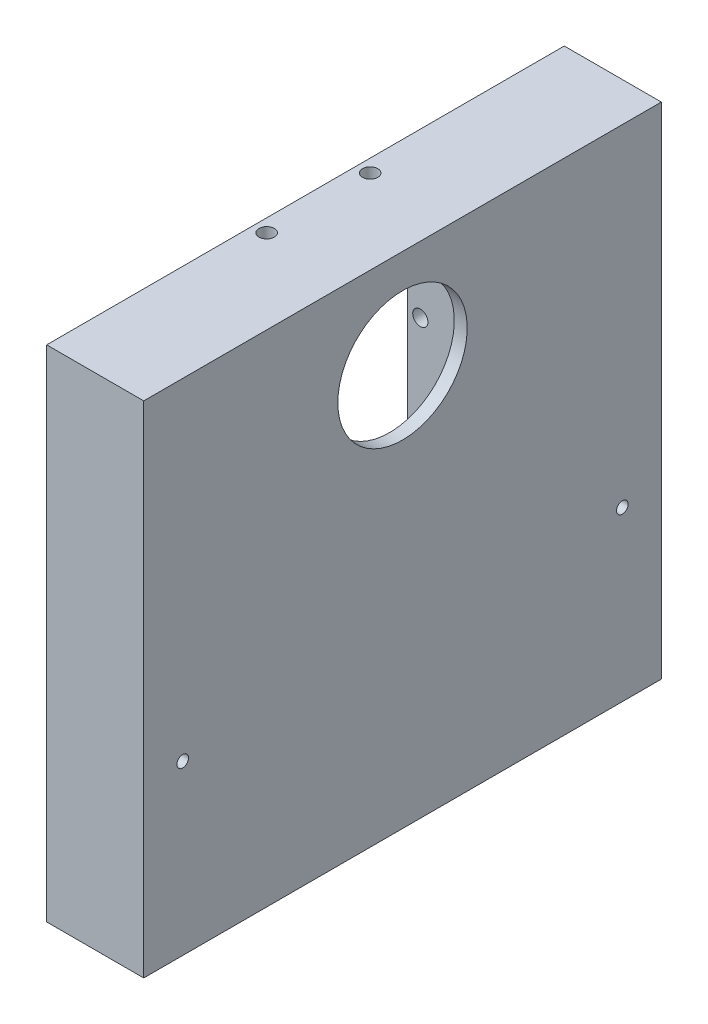
from build123d import *

# Parameters (mm, degrees)
SKETCH_1_W                    = 100
SKETCH_1_H                    = 80
EXTRUDE_1_DEPTH               = 19
SKETCH_2_W                    = 72
SKETCH_2_H                    = 92
CUT_EXTRUDE_1_DEPTH           = 17
SKETCH_3_W                    = 36.5
SKETCH_3_H                    = 54.5
EXTRUDE_2_DEPTH               = 17
SKETCH_4_W                    = 31.5
SKETCH_4_H                    = 49.5
CUT_EXTRUDE_2_DEPTH           = 17
HOLE_WIZARD_20_0_20_1_D       = 20
HOLE_WIZARD_20_0_20_1_DEPTH   = 2
HOLE_WIZARD_2_35_2_35_1_D     = 2.35
HOLE_WIZARD_2_35_2_35_1_DEPTH = 2.5
HOLE_WIZARD_2_35_2_35_2_D     = 2.35
HOLE_WIZARD_2_35_2_35_2_DEPTH = 2.5
HOLE_WIZARD_2_35_2_35_3_D     = 2.35
HOLE_WIZARD_2_35_2_35_3_DEPTH = 2.5
HOLE_WIZARD_2_35_2_35_4_D     = 2.35
HOLE_WIZARD_2_35_2_35_4_DEPTH = 2.5
SKETCH_22_W                   = 13
SKETCH_22_H                   = 36.5
CUT_EXTRUDE_5_DEPTH           = 10
SKETCH_23_W                   = 80
SKETCH_23_H                   = 22.75
CUT_EXTRUDE_6_DEPTH           = 19
SKETCH_24_W                   = 17
SKETCH_24_H                   = 17.75
EXTRUDE_3_DEPTH               = 4
SKETCH_27_W                   = 4
SKETCH_27_H                   = 77.25
CUT_EXTRUDE_7_DEPTH           = 80
SKETCH_28_R                   = 0.9
CUT_EXTRUDE_8_DEPTH           = 10


with BuildPart() as part:
    # 스케치1 → 보스-돌출1 (new body)
    with BuildSketch(Plane(origin=(0, 0, 0), x_dir=(0, -1, 0), z_dir=(-1, 0, 0))):
        with Locations((-23.25, -14.25)):
            Rectangle(SKETCH_1_W, SKETCH_1_H)
    extrude(amount=-EXTRUDE_1_DEPTH)

    # 스케치2 → 컷-돌출1 (cut)
    with BuildSketch(Plane.ZY):
        with Locations((-14.25, 23.25)):
            Rectangle(SKETCH_2_W, SKETCH_2_H)
    extrude(amount=-CUT_EXTRUDE_1_DEPTH, mode=Mode.SUBTRACT)

    # 스케치3 → 보스-돌출2 (add)
    with BuildSketch(Plane.ZY.offset(-17)):
        with Locations((-14.25, 23.25)):
            Rectangle(SKETCH_3_W, SKETCH_3_H)
    extrude(amount=EXTRUDE_2_DEPTH)

    # 스케치4 → 컷-돌출2 (cut)
    with BuildSketch(Plane.ZY):
        with Locations((-14.25, 23.25)):
            Rectangle(SKETCH_4_W, SKETCH_4_H)
    extrude(amount=-CUT_EXTRUDE_2_DEPTH, mode=Mode.SUBTRACT)

    # Ø20.0 (20) 지름 구멍1
    with Locations(Plane.ZY.offset(-17)):
        with Locations((-14.25, 35.25)):
            Hole(HOLE_WIZARD_20_0_20_1_D / 2, depth=HOLE_WIZARD_20_0_20_1_DEPTH)

    # Ø2.35 (2.35) 지름 구멍1
    with Locations(Plane(origin=(0, -1.5, 0), x_dir=(1, 0, 0), z_dir=(0, 1, 0))):
        with Locations((6, 6.25), (6, 22.25)):
            Hole(HOLE_WIZARD_2_35_2_35_1_D / 2, depth=HOLE_WIZARD_2_35_2_35_1_DEPTH)

    # Ø2.35 (2.35) 지름 구멍2
    with Locations(Plane.XY.offset(-30)):
        with Locations((6, 27.25), (6, 3.25)):
            Hole(HOLE_WIZARD_2_35_2_35_2_D / 2, depth=HOLE_WIZARD_2_35_2_35_2_DEPTH)

    # Ø2.35 (2.35) 지름 구멍3
    with Locations(Plane(origin=(0, 48, 0), x_dir=(-1, 0, 0), z_dir=(0, -1, 0))):
        with Locations((-6, 6.25), (-6, 22.25)):
            Hole(HOLE_WIZARD_2_35_2_35_3_D / 2, depth=HOLE_WIZARD_2_35_2_35_3_DEPTH)

    # Ø2.35 (2.35) 지름 구멍4
    with Locations(Plane(origin=(0, 0, 1.5), x_dir=(-1, 0, 0), z_dir=(0, 0, -1))):
        with Locations((-6, 27.25), (-6, 3.25)):
            Hole(HOLE_WIZARD_2_35_2_35_4_D / 2, depth=HOLE_WIZARD_2_35_2_35_4_DEPTH)

    # 스케치22 → 컷-돌출5 (cut)
    with BuildSketch(Plane.XZ.offset(26.75)):
        with Locations((6.5, -14.25)):
            Rectangle(SKETCH_22_W, SKETCH_22_H)
    extrude(amount=-CUT_EXTRUDE_5_DEPTH, mode=Mode.SUBTRACT)

    # 스케치23 → 컷-돌출6 (cut)
    with BuildSketch(Plane.ZY):
        with Locations((-14.25, 61.875)):
            Rectangle(SKETCH_23_W, SKETCH_23_H)
    extrude(amount=-CUT_EXTRUDE_6_DEPTH, mode=Mode.SUBTRACT)

    # 스케치24 → 보스-돌출3 (add)
    with BuildSketch(Plane(origin=(0, 50.5, 0), x_dir=(1, 0, 0), z_dir=(0, 1, 0))):
        with Locations((8.5, -12.875)):
            Rectangle(SKETCH_24_W, SKETCH_24_H)
        with Locations((8.5, 41.375)):
            Rectangle(SKETCH_24_W, SKETCH_24_H)
    extrude(amount=-EXTRUDE_3_DEPTH)

    # 스케치27 → 컷-돌출7 (cut)
    with BuildSketch(Plane(origin=(0, 0, -54.25), x_dir=(-1, 0, 0), z_dir=(0, 0, -1))):
        with Locations((-2, 11.875)):
            Rectangle(SKETCH_27_W, SKETCH_27_H)
    extrude(amount=-CUT_EXTRUDE_7_DEPTH, mode=Mode.SUBTRACT)

    # 스케치28 → 컷-돌출8 (cut)
    with BuildSketch(Plane(origin=(19, 0, 0), x_dir=(0, 0, -1), z_dir=(1, 0, 0))):
        with Locations((-19.725, -0.75)):
            Circle(SKETCH_28_R)
        with Locations((48.225, -0.75)):
            Circle(SKETCH_28_R)
    extrude(amount=-CUT_EXTRUDE_8_DEPTH, mode=Mode.SUBTRACT)


solid = part.part
